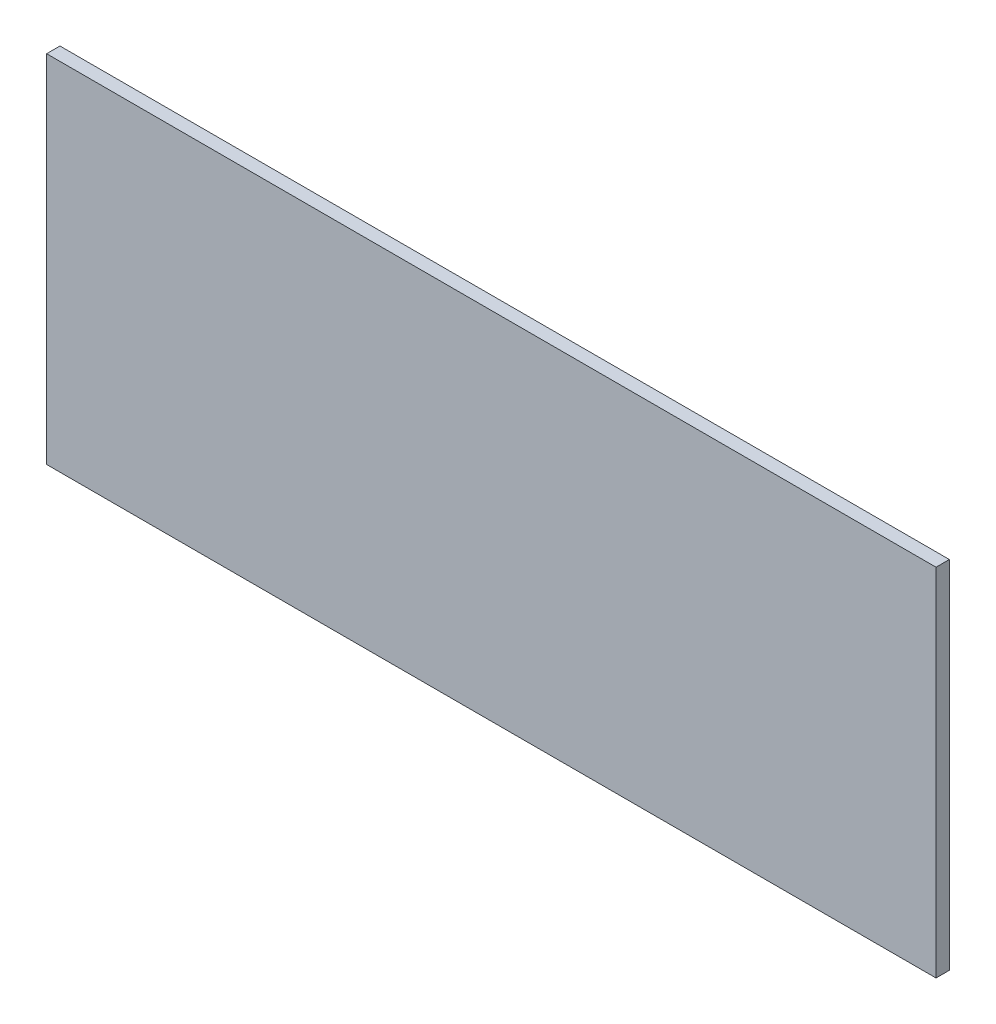
from build123d import *

# Parameters (mm, degrees)
SKETCH1_W           = 200
SKETCH1_H           = 80
BOSS_EXTRUDE1_DEPTH = 3


with BuildPart() as part:
    # Sketch1 → Boss-Extrude1 (new body)
    with BuildSketch(Plane.XY):
        Rectangle(SKETCH1_W, SKETCH1_H)
    extrude(amount=BOSS_EXTRUDE1_DEPTH)


solid = part.part
